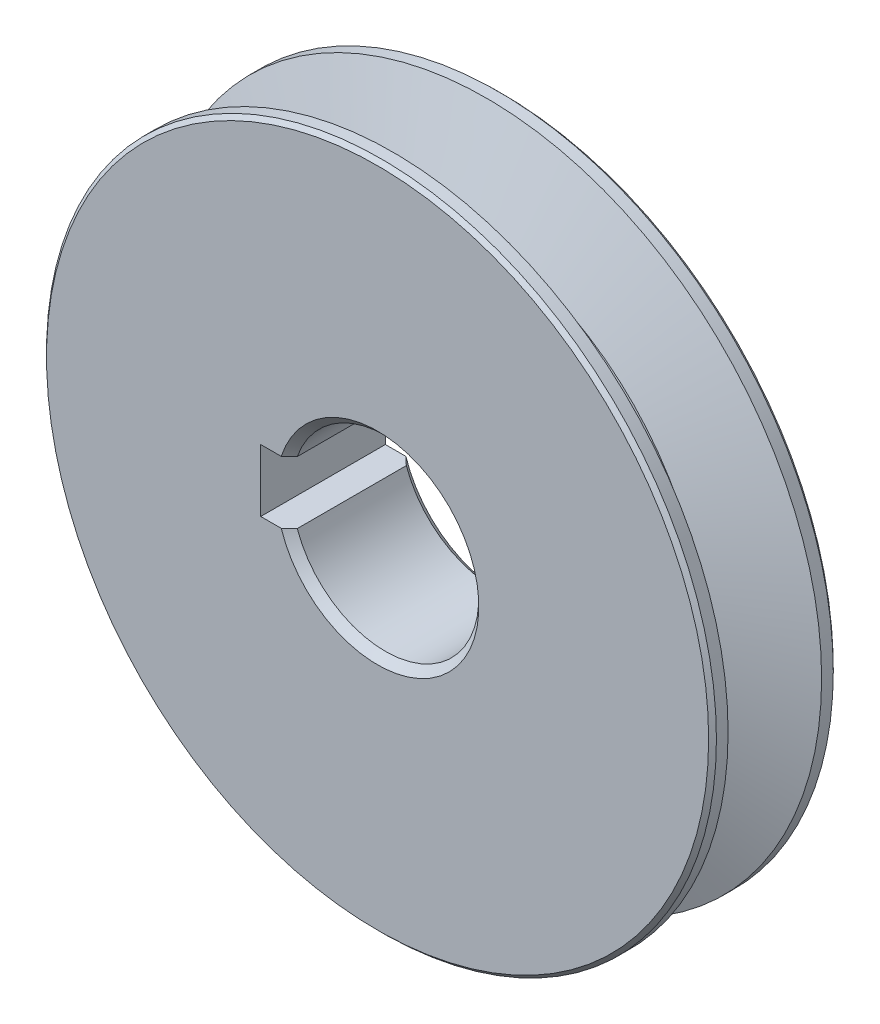
from build123d import *

# Parameters (mm, degrees)
CUT_EXTRUDE1_DEPTH = 17
SKETCH3_W          = 12
SKETCH3_H          = 16
CHAMFER1_SIZE2     = 1.000000021
CHAMFER1_SIZE      = 1.000000018
CHAMFER2_SIZE      = 0.5
SCALE1_SCALE       = 0.75


with BuildPart() as part:
    # Sketch1 → Revolve1 (revolve)
    with BuildSketch(Plane(origin=(0, 0, 0), x_dir=(1, 0, 0), z_dir=(0, 1, 0))):
        Polygon((43, 8), (0, 8), (0, -8), (43, -8), (43, -6.003672577), (32, -2), (32, 2), (43, 6.003672577), align=None)
    revolve(axis=Axis((0, 0, -8), (0, 0, 1)))

    # Sketch2 → Cut-Extrude1 (cut, through all)
    with BuildSketch(Plane.XY.offset(8)):
        with BuildLine():
            Line((-15, -4), (-11.313708499, -4))
            ThreePointArc((-11.313708499, -4), (-12, -1e-09), (-11.313708499, 3.999999999))
            Line((-11.313708499, 3.999999999), (-15, 3.999999999))
            Line((-15, 3.999999999), (-15, -4))
        make_face()
    extrude(amount=-CUT_EXTRUDE1_DEPTH, mode=Mode.SUBTRACT)

    # Sketch3 → Cut-Revolve1 (revolve, cut)
    with BuildSketch(Plane(origin=(0, 0, 0), x_dir=(1, 0, 0), z_dir=(0, 1, 0))):
        with Locations((6, 0)):
            Rectangle(SKETCH3_W, SKETCH3_H)
    revolve(axis=Axis((0, 0, -8), (0, 0, 1)), mode=Mode.SUBTRACT)

    # Chamfer1
    chamfer1_edges = [part.edges().sort_by_distance(p)[0] for p in [
        (12, 1e-09, -8),
        (12, 1e-09, 8),
    ]]
    chamfer(chamfer1_edges, length=CHAMFER1_SIZE, length2=CHAMFER1_SIZE2)

    # Chamfer2
    chamfer2_edges = [part.edges().sort_by_distance(p)[0] for p in [
        (-43, 0, 8),
        (-43, 0, -8),
    ]]
    chamfer(chamfer2_edges, length=CHAMFER2_SIZE)


with BuildPart() as part_1:
    # Scale1: scaled about (0.084922045, 0, 0)
    add(part.part.scale(SCALE1_SCALE).moved(Location((0.021230511, 0, 0))))


solid = part_1.part
